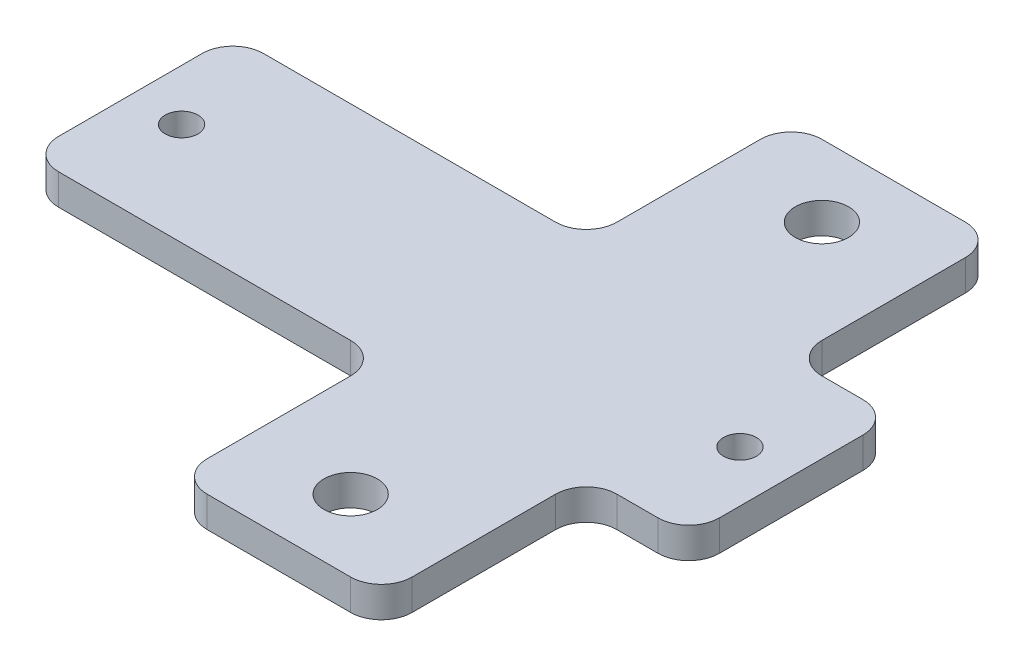
from build123d import *

# Parameters (mm, degrees)
SKETCH_1_W      = 20
SKETCH_1_H      = 60
SKETCH_1_R      = 2.6
EXTRUDE_1_DEPTH = 3
SKETCH_2_W      = 34.5
SKETCH_2_H      = 20
SKETCH_2_R      = 1.6
SKETCH_2_W_2    = 10
EXTRUDE_2_DEPTH = 3
FILLET_1_R      = 3


with BuildPart() as part:
    # 草图1 → 凸台-拉伸1 (new body)
    with BuildSketch(Plane(origin=(0, 0, 0), x_dir=(1, 0, 0), z_dir=(0, 1, 0))):
        with Locations((10, 30)):
            Rectangle(SKETCH_1_W, SKETCH_1_H)
        with Locations((10, 7)):
            Circle(SKETCH_1_R, mode=Mode.SUBTRACT)
        with Locations((10, 53)):
            Circle(SKETCH_1_R, mode=Mode.SUBTRACT)
    extrude(amount=EXTRUDE_1_DEPTH)

    # 草图2 → 凸台-拉伸2 (add)
    with BuildSketch(Plane(origin=(0, 3, 0), x_dir=(1, 0, 0), z_dir=(0, 1, 0))):
        with Locations((-17.25, 30)):
            Rectangle(SKETCH_2_W, SKETCH_2_H)
        with Locations((-29.5, 30)):
            Circle(SKETCH_2_R, mode=Mode.SUBTRACT)
        with Locations((25, 30)):
            Rectangle(SKETCH_2_W_2, SKETCH_2_H)
        with Locations((25, 30)):
            Circle(SKETCH_2_R, mode=Mode.SUBTRACT)
    extrude(amount=-EXTRUDE_2_DEPTH)

    # 圆角1
    fillet_1_edges = [part.edges().sort_by_distance(p)[0] for p in [
        (0, 1.5, -40),
        (0, 1.5, -20),
        (-34.5, 1.5, -20),
        (-34.5, 1.5, -40),
        (20, 1.5, -20),
        (20, 1.5, -40),
        (30, 1.5, -40),
        (30, 1.5, -20),
        (0, 1.5, -60),
        (20, 1.5, -60),
        (20, 1.5, 0),
        (0, 1.5, 0),
    ]]
    fillet(fillet_1_edges, radius=FILLET_1_R)


solid = part.part
